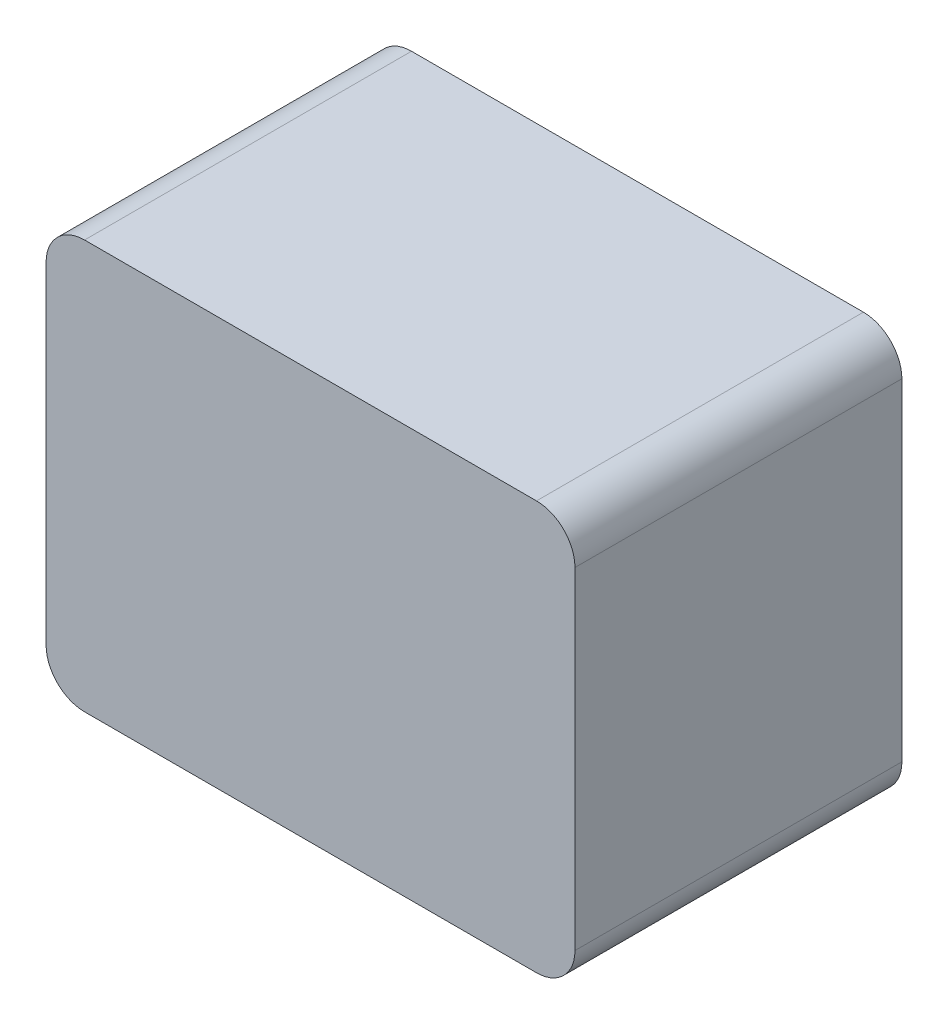
from build123d import *

# Parameters (mm, degrees)
EXTRUDE_1_DEPTH = 68


with BuildPart() as part:
    # 草图1 → 凸台-拉伸1 (new body)
    with BuildSketch(Plane.XY):
        with BuildLine():
            Line((-95.212025316, 68.117088608), (-1.212025316, 68.117088608))
            ThreePointArc((-1.212025316, 68.117088608), (4.444828933, 65.773942857), (6.787974684, 60.117088608))
            Line((6.787974684, 60.117088608), (6.787974684, -8.882911392))
            ThreePointArc((6.787974684, -8.882911392), (4.444828933, -14.539765642), (-1.212025316, -16.882911392))
            Line((-1.212025316, -16.882911392), (-95.212025316, -16.882911392))
            ThreePointArc((-95.212025316, -16.882911392), (-100.868879566, -14.539765642), (-103.212025316, -8.882911392))
            Line((-103.212025316, -8.882911392), (-103.212025316, 60.117088608))
            ThreePointArc((-103.212025316, 60.117088608), (-100.868879566, 65.773942857), (-95.212025316, 68.117088608))
        make_face()
    extrude(amount=EXTRUDE_1_DEPTH)


solid = part.part
